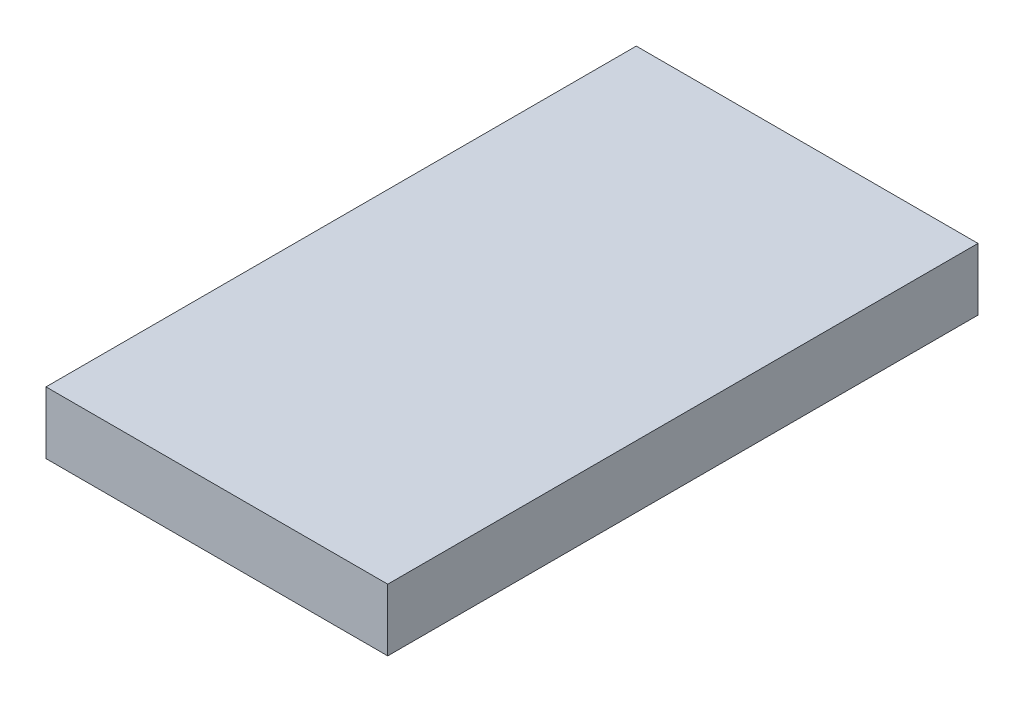
from build123d import *

# Parameters (mm, degrees)
SKETCH1_W           = 27.5
SKETCH1_H           = 47.5
BOSS_EXTRUDE1_DEPTH = 5


with BuildPart() as part:
    # Sketch1 → Boss-Extrude1 (new body)
    with BuildSketch(Plane(origin=(0, 0, 0), x_dir=(1, 0, 0), z_dir=(0, 1, 0))):
        Rectangle(SKETCH1_W, SKETCH1_H)
    extrude(amount=BOSS_EXTRUDE1_DEPTH)


solid = part.part
